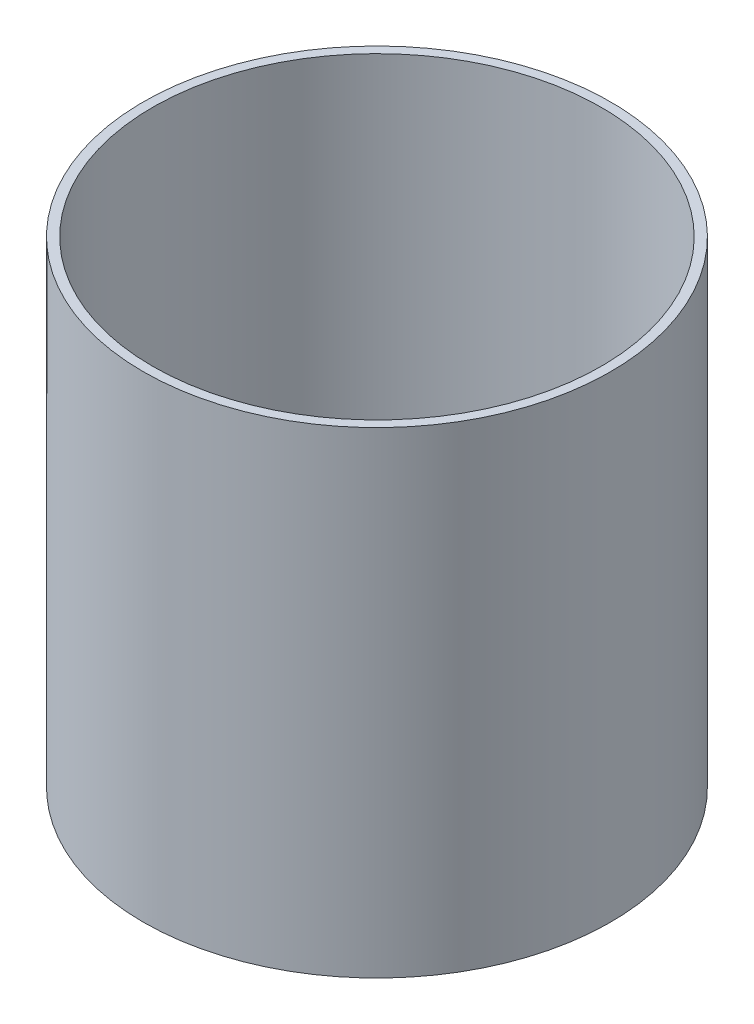
from build123d import *

# Parameters (mm, degrees)
SKETCH1_R           = 50
BOSS_EXTRUDE1_DEPTH = 2
SKETCH4_R           = 2
CUT_EXTRUDE1_DEPTH  = 2
SKETCH5_R           = 50
SKETCH5_R_2         = 48
BOSS_EXTRUDE2_DEPTH = 100
SKETCH6_R           = 2
BOSS_EXTRUDE3_DEPTH = 20
SKETCH7_R           = 3.5
CUT_EXTRUDE2_DEPTH  = 5
SKETCH8_R           = 1.45
CUT_EXTRUDE3_DEPTH  = 10


with BuildPart() as part:
    # Sketch1 → Boss-Extrude1 (new body)
    with BuildSketch(Plane(origin=(0, 0, 0), x_dir=(1, 0, 0), z_dir=(0, 1, 0))):
        Circle(SKETCH1_R)
    extrude(amount=BOSS_EXTRUDE1_DEPTH)

    # Sketch4 → Cut-Extrude1 (cut)
    with BuildSketch(Plane(origin=(0, 2, 0), x_dir=(1, 0, 0), z_dir=(0, 1, 0))):
        with Locations((-7.5, 0)):
            Circle(SKETCH4_R)
        with Locations((7.5, 0)):
            Circle(SKETCH4_R)
    extrude(amount=-CUT_EXTRUDE1_DEPTH, mode=Mode.SUBTRACT)

    # Sketch5 → Boss-Extrude2 (add)
    with BuildSketch(Plane(origin=(0, 2, 0), x_dir=(1, 0, 0), z_dir=(0, 1, 0))):
        Circle(SKETCH5_R)
        Circle(SKETCH5_R_2, mode=Mode.SUBTRACT)
    extrude(amount=BOSS_EXTRUDE2_DEPTH)

    # Sketch6 → Boss-Extrude3 (add)
    with BuildSketch(Plane(origin=(0, 2, 0), x_dir=(1, 0, 0), z_dir=(0, 1, 0))):
        Circle(SKETCH6_R)
    extrude(amount=BOSS_EXTRUDE3_DEPTH)

    # Sketch7 → Cut-Extrude2 (cut)
    with BuildSketch(Plane(origin=(0, 2, 0), x_dir=(1, 0, 0), z_dir=(0, 1, 0))):
        with Locations((0, -35)):
            Circle(SKETCH7_R)
    extrude(amount=-CUT_EXTRUDE2_DEPTH, mode=Mode.SUBTRACT)

    # Sketch8 → Cut-Extrude3 (cut)
    with BuildSketch(Plane(origin=(0, 2, 0), x_dir=(1, 0, 0), z_dir=(0, 1, 0))):
        with Locations((0.238867715, -32.008273773)):
            Circle(SKETCH8_R)
        with Locations((-32.724876918, 0.318490286)):
            Circle(SKETCH8_R)
        with Locations((-0.238867715, 32.963744632)):
            Circle(SKETCH8_R)
        with Locations((31.769406059, 0.159245143)):
            Circle(SKETCH8_R)
    extrude(amount=-CUT_EXTRUDE3_DEPTH, mode=Mode.SUBTRACT)


solid = part.part
